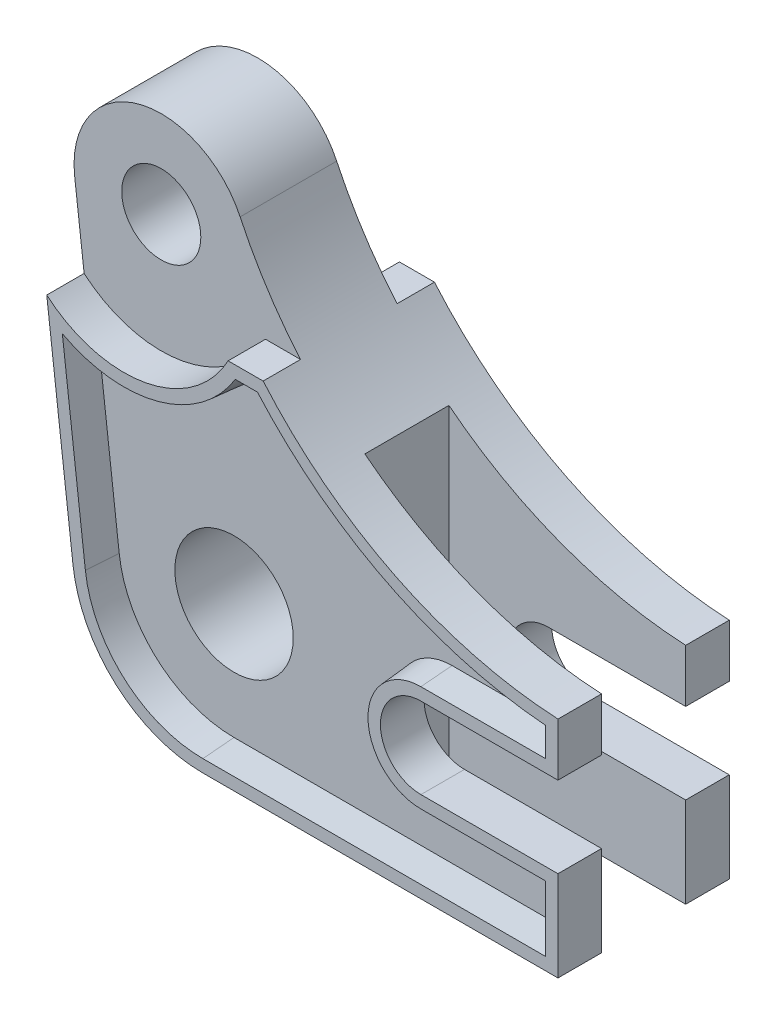
from build123d import *

# Parameters (mm, degrees)
SKETCH1_R           = 6.35
SKETCH1_R_2         = 9.5
BOSS_EXTRUDE1_DEPTH = 13.75
SKETCH3_R           = 6.35
CUT_EXTRUDE1_DEPTH  = 6
SKETCH4_W           = 38
SKETCH4_H           = 13.5
CUT_EXTRUDE2_DEPTH  = 83.330365488
CUT_EXTRUDE3_DEPTH  = 5
CUT_EXTRUDE3_DRAFT  = -5


with BuildPart() as part:
    # Sketch1 → Boss-Extrude1 (new body, symmetric)
    with BuildSketch(Plane.XY):
        with BuildLine():
            Line((0, 0), (0, 14.5))
            Line((0, 14.5), (-22, 14.5))
            ThreePointArc((-22, 14.5), (-28.5, 21), (-22, 27.5))
            Line((-22, 27.5), (0, 27.5))
            Line((0, 27.5), (0, 36))
            ThreePointArc((0, 36), (-33.793604177, 47.289264213), (-57.021595035, 74.306214643))
            ThreePointArc((-57.021595035, 74.306214643), (-73.547441909, 81.786196516), (-83.58403216, 66.675915252))
            Line((-83.58403216, 66.675915252), (-77.852848425, 18.518324646))
            ThreePointArc((-77.852848425, 18.518324646), (-70.944260783, 5.297847561), (-57, 0))
            Line((-57, 0), (0, 0))
        make_face()
        with Locations((-69.68213321, 68.330365488)):
            Circle(SKETCH1_R, mode=Mode.SUBTRACT)
        with Locations((-57, 21)):
            Circle(SKETCH1_R_2, mode=Mode.SUBTRACT)
    extrude(amount=BOSS_EXTRUDE1_DEPTH, both=True)

    # Sketch3 → Cut-Extrude1 (cut)
    with BuildSketch(Plane.XY.offset(13.75)):
        with BuildLine():
            ThreePointArc((-57.021595035, 74.306214643), (-73.547441909, 81.786196516), (-83.58403216, 66.675915252))
            Line((-83.58403216, 66.675915252), (-82.066046583, 53.920692017))
            ThreePointArc((-82.066046583, 53.920692017), (-66.211511297, 49.650034026), (-52.948932679, 59.330365488))
            Line((-52.948932679, 59.330365488), (-47.326454774, 59.330365488))
            ThreePointArc((-47.326454774, 59.330365488), (-52.674708251, 66.494155172), (-57.021595035, 74.306214643))
        make_face()
        with Locations((-69.68213321, 68.330365488)):
            Circle(SKETCH3_R, mode=Mode.SUBTRACT)
    cut_extrude1 = extrude(amount=-CUT_EXTRUDE1_DEPTH, mode=Mode.SUBTRACT)

    # Mirror1: Cut-Extrude1 across plane
    add(cut_extrude1.mirror(Plane.XY), mode=Mode.SUBTRACT)

    # Sketch4 → Cut-Extrude2 (cut, through all)
    with BuildSketch(Plane.XZ):
        with Locations((-19, 0)):
            Rectangle(SKETCH4_W, SKETCH4_H)
    extrude(amount=-CUT_EXTRUDE2_DEPTH, mode=Mode.SUBTRACT)


with BuildPart() as cut_extrude3_tool:
    # Sketch5 → Cut-Extrude3 (with draft: the straight prism first)
    with BuildSketch(Plane.XY.offset(13.75)):
        with BuildLine():
            ThreePointArc((-51.79358939, 57.330365488), (-64.185224634, 48.062558599), (-79.561455233, 49.799337552))
            Line((-79.561455233, 49.799337552), (-75.866862861, 18.75467468))
            ThreePointArc((-75.866862861, 18.75467468), (-69.616235946, 6.79329065), (-57, 2))
            Line((-57, 2), (-2, 2))
            Line((-2, 2), (-2, 12.5))
            Line((-2, 12.5), (-22, 12.5))
            ThreePointArc((-22, 12.5), (-30.5, 21), (-22, 29.5))
            Line((-22, 29.5), (-2, 29.5))
            Line((-2, 29.5), (-2, 34.12995492))
            ThreePointArc((-2, 34.12995492), (-27.376011233, 41.232719036), (-48.238824631, 57.330365488))
            Line((-48.238824631, 57.330365488), (-51.79358939, 57.330365488))
        make_face()
    extrude(amount=-CUT_EXTRUDE3_DEPTH)
    # Cut-Extrude3: the draft: its side faces are tilted about the plane it starts from
    cut_extrude3_sides = [cut_extrude3_tool.faces().sort_by_distance(p)[0] for p in [
        (-50.01620701, 57.330365488, 11.25),
        (-64.185224634, 48.062558599, 11.25),
        (-77.714159047, 34.277006116, 11.25),
        (-69.616235946, 6.79329065, 11.25),
        (-29.5, 2, 11.25),
        (-2, 7.25, 11.25),
        (-12, 12.5, 11.25),
        (-30.5, 21, 11.25),
        (-12, 29.5, 11.25),
        (-2, 31.81497746, 11.25),
        (-27.376011233, 41.232719036, 11.25),
    ]]
    draft(cut_extrude3_sides, Plane.XY.offset(13.75), CUT_EXTRUDE3_DRAFT)


with BuildPart() as part_1:
    add(part.part)

    # Cut-Extrude3: cut by cut_extrude3_tool
    add(cut_extrude3_tool.part, mode=Mode.SUBTRACT)


solid = part_1.part
